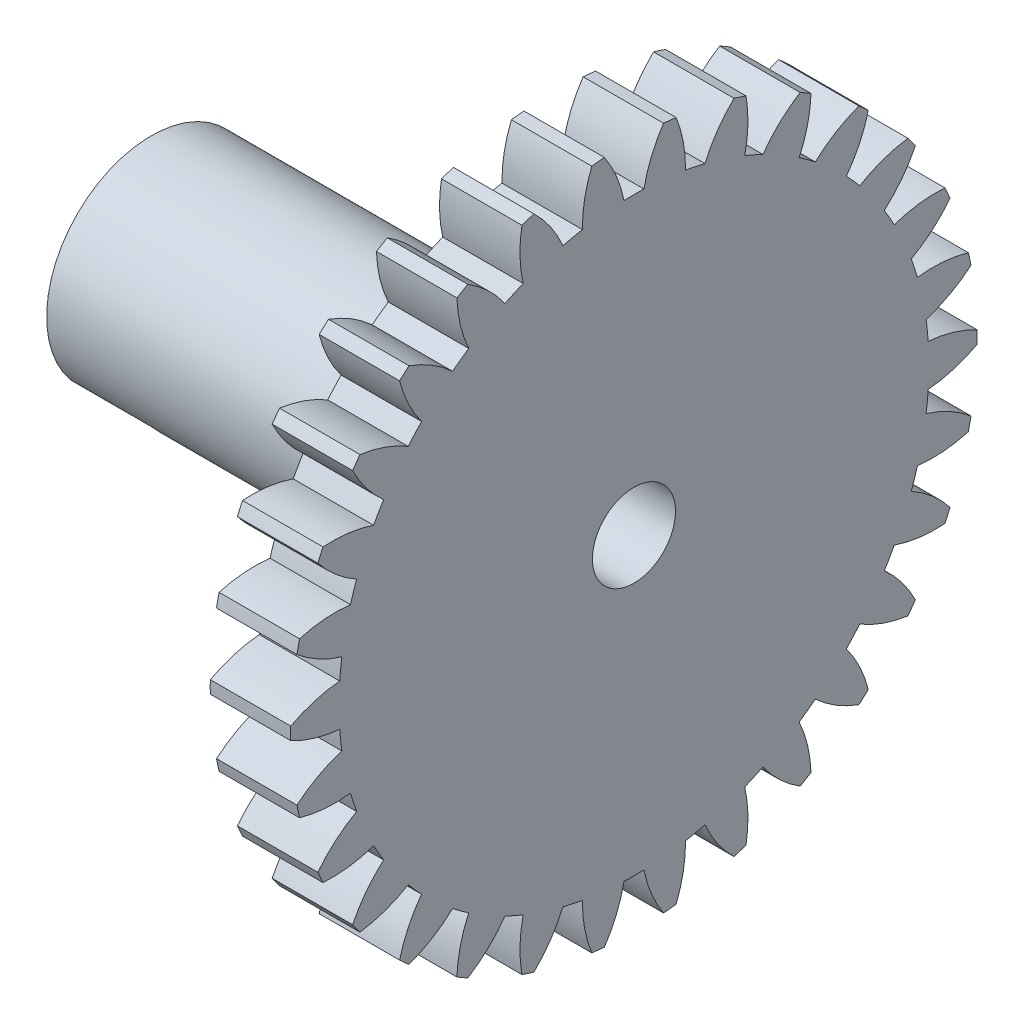
from build123d import *

# Parameters (mm, degrees)
BASPROSKE_W         = 5.5
BASPROSKE_H         = 12.8
TOOTHCUT_DEPTH      = 19.919038031
TEETHCUTS_COUNT     = 30
HUBNEAONESKE_R      = 1.9
HUBNEARONE_DEPTH    = 5.5000508
BORSKE_R            = 0.4
BORE_DEPTH          = 11.0000508
SKETCH1_R           = 3.9
BOSS_EXTRUDE1_DEPTH = 15
SKETCH2_R           = 1.55
CUT_EXTRUDE1_DEPTH  = 28
CUT_EXTRUDE2_DEPTH  = 3
CUT_EXTRUDE3_DEPTH  = 2.5


with BuildPart() as part:
    # BasProSke → Base-Revolve (revolve)
    with BuildSketch(Plane(origin=(0, 0, 0), x_dir=(1, 0, 0), z_dir=(0, 1, 0)), mode=Mode.PRIVATE) as base_revolve_sk:
        with Locations((2.75, 6.4)):
            Rectangle(BASPROSKE_W, BASPROSKE_H)
    revolve(base_revolve_sk.sketch.rotate(Axis((-10, 0, 0), (1, 0, 0)), 180), axis=Axis((-10, 0, 0), (1, 0, 0)))

    # TooCutSke → ToothCut (cut, through all)
    with BuildSketch(Plane(origin=(0, 0, 0), x_dir=(0, 0, -1), z_dir=(1, 0, 0))):
        with BuildLine():
            ThreePointArc((0.37243947, 10.992692566), (0, 10.999), (-0.37243947, 10.992692566))
            ThreePointArc((-0.37243947, 10.992692566), (-0.655704499, 11.922595954), (-1.120515575, 12.776358245))
            ThreePointArc((-1.120515575, 12.776358245), (0, 12.8254), (1.120515575, 12.776358245))
            ThreePointArc((1.120515575, 12.776358245), (0.655704499, 11.922595954), (0.37243947, 10.992692566))
        make_face()
    toothcut = extrude(amount=TOOTHCUT_DEPTH, mode=Mode.SUBTRACT)

    # TeethCuts: ToothCut ×30 about axis
    teethcuts_axis = Axis((0, 0, 0), (1, 0, 0))
    for i in range(1, TEETHCUTS_COUNT):
        add(toothcut.rotate(teethcuts_axis, i * 360 / TEETHCUTS_COUNT), mode=Mode.SUBTRACT)

    # HubNeaOneSke → HubNearOne (add)
    with BuildSketch(Plane.ZY):
        with Locations(Location((0, 0, 0), (0, 0, 180))):
            Circle(HUBNEAONESKE_R)
    extrude(amount=HUBNEARONE_DEPTH)

    # BorSke → Bore (cut, symmetric)
    with BuildSketch(Plane(origin=(0, 0, 0), x_dir=(0, 0, -1), z_dir=(1, 0, 0))):
        with Locations(Location((0, 0, 0), (0, 0, 180))):
            Circle(BORSKE_R)
    extrude(amount=BORE_DEPTH, both=True, mode=Mode.SUBTRACT)

    # Sketch1 → Boss-Extrude1 (add)
    with BuildSketch(Plane.ZY):
        with Locations(Location((0, 0, 0), (0, 0, 180))):
            Circle(SKETCH1_R)
    extrude(amount=BOSS_EXTRUDE1_DEPTH)

    # Sketch2 → Cut-Extrude1 (cut)
    with BuildSketch(Plane.ZY.offset(15)):
        Circle(SKETCH2_R)
    extrude(amount=-CUT_EXTRUDE1_DEPTH, mode=Mode.SUBTRACT)

    # Sketch3 → Cut-Extrude2 (cut)
    with BuildSketch(Plane.ZY.offset(15)):
        with BuildLine():
            Line((-3, -2.491987159), (3, -2.491987159))
            ThreePointArc((3, -2.491987159), (0, -3.9), (-3, -2.491987159))
        make_face()
    extrude(amount=-CUT_EXTRUDE2_DEPTH, mode=Mode.SUBTRACT)

    # Sketch4 → Cut-Extrude3 (cut)
    with BuildSketch(Plane(origin=(5.5, 0, 0), x_dir=(0, 0, -1), z_dir=(1, 0, 0))):
        with BuildLine():
            ThreePointArc((-12.797844972, -0.234870354), (-11.911881767, -0.598311695), (-10.971403971, -0.778650053))
            ThreePointArc((-10.971403971, -0.778650053), (-10.938746327, -1.149708567), (-10.89354292, -1.519448469))
            ThreePointArc((-10.89354292, -1.519448469), (-11.775974567, -1.89138233), (-12.567013646, -2.431083714))
            ThreePointArc((-12.567013646, -2.431083714), (-12.520289289, -2.661269642), (-12.469349061, -2.89055946))
            ThreePointArc((-12.469349061, -2.89055946), (-11.527182574, -3.061856628), (-10.569762022, -3.042717832))
            ThreePointArc((-10.569762022, -3.042717832), (-10.460670623, -3.398877921), (-10.339581771, -3.751139802))
            ThreePointArc((-10.339581771, -3.751139802), (-11.125400771, -4.298413871), (-11.786943521, -4.990787758))
            ThreePointArc((-11.786943521, -4.990787758), (-11.693381858, -5.206229031), (-11.595882762, -5.419917247))
            ThreePointArc((-11.595882762, -5.419917247), (-10.63869019, -5.391583734), (-9.706170753, -5.17380424))
            ThreePointArc((-9.706170753, -5.17380424), (-9.525413416, -5.4995), (-9.333731283, -5.818888325))
            ThreePointArc((-9.333731283, -5.818888325), (-9.988593575, -6.517584101), (-10.491727404, -7.332370428))
            ThreePointArc((-10.491727404, -7.332370428), (-10.355417528, -7.523651229), (-10.215620743, -7.712398643))
            ThreePointArc((-10.215620743, -7.712398643), (-9.285235994, -7.485672759), (-8.418373247, -7.078770577))
            ThreePointArc((-8.418373247, -7.078770577), (-8.173849935, -7.359767539), (-7.91995195, -7.632323507))
            ThreePointArc((-7.91995195, -7.632323507), (-8.41523691, -8.45190463), (-8.737972454, -9.353493326))
            ThreePointArc((-8.737972454, -9.353493326), (-8.564871761, -9.512253766), (-8.388887078, -9.66781121))
            ThreePointArc((-8.388887078, -9.66781121), (-7.52597243, -9.252601964), (-6.762652434, -8.674360672))
            ThreePointArc((-6.762652434, -8.674360672), (-6.46504999, -8.898377921), (-6.160032712, -9.112189527))
            ThreePointArc((-6.160032712, -9.112189527), (-6.474094011, -10.01683637), (-6.602326179, -10.965823682))
            ThreePointArc((-6.602326179, -10.965823682), (-6.4, -11.085125168), (-6.195518793, -11.200694036))
            ThreePointArc((-6.195518793, -11.200694036), (-5.437787756, -10.615148065), (-4.811371258, -9.890839581))
            ThreePointArc((-4.811371258, -9.890839581), (-4.473696337, -10.048086489), (-4.130890486, -10.19380914))
            ThreePointArc((-4.130890486, -10.19380914), (-4.250002137, -11.143984294), (-4.178126568, -12.098894924))
            ThreePointArc((-4.178126568, -12.098894924), (-3.955417528, -12.173523409), (-3.731376607, -12.244052786))
            ThreePointArc((-3.731376607, -12.244052786), (-3.111945665, -11.513761258), (-2.649810072, -10.675041339))
            ThreePointArc((-2.649810072, -10.675041339), (-2.286820687, -10.75864546), (-1.921208524, -10.829910379))
            ThreePointArc((-1.921208524, -10.829910379), (-1.840164777, -11.78408663), (-1.571322777, -12.703186401))
            ThreePointArc((-1.571322777, -12.703186401), (-1.33796433, -12.729880261), (-1.104155359, -12.752287675))
            ThreePointArc((-1.104155359, -12.752287675), (-0.650096615, -11.909167834), (-0.37243947, -10.992692566))
            ThreePointArc((-0.37243947, -10.992692566), (0, -10.999), (0.37243947, -10.992692566))
            ThreePointArc((0.37243947, -10.992692566), (0.650096615, -11.909167834), (1.104155359, -12.752287675))
            ThreePointArc((1.104155359, -12.752287675), (1.33796433, -12.729880261), (1.571322777, -12.703186401))
            ThreePointArc((1.571322777, -12.703186401), (1.840164777, -11.78408663), (1.921208524, -10.829910379))
            ThreePointArc((1.921208524, -10.829910379), (2.286820687, -10.75864546), (2.649810072, -10.675041339))
            ThreePointArc((2.649810072, -10.675041339), (3.111945665, -11.513761258), (3.731376607, -12.244052786))
            ThreePointArc((3.731376607, -12.244052786), (3.955417528, -12.173523409), (4.178126568, -12.098894924))
            ThreePointArc((4.178126568, -12.098894924), (4.250002137, -11.143984294), (4.130890486, -10.19380914))
            ThreePointArc((4.130890486, -10.19380914), (4.473696337, -10.048086489), (4.811371258, -9.890839581))
            ThreePointArc((4.811371258, -9.890839581), (5.437787756, -10.615148065), (6.195518793, -11.200694036))
            ThreePointArc((6.195518793, -11.200694036), (6.4, -11.085125168), (6.602326179, -10.965823682))
            ThreePointArc((6.602326179, -10.965823682), (6.474094011, -10.01683637), (6.160032712, -9.112189527))
            ThreePointArc((6.160032712, -9.112189527), (6.46504999, -8.898377921), (6.762652434, -8.674360672))
            ThreePointArc((6.762652434, -8.674360672), (7.52597243, -9.252601964), (8.388887078, -9.66781121))
            ThreePointArc((8.388887078, -9.66781121), (8.564871761, -9.512253766), (8.737972454, -9.353493326))
            ThreePointArc((8.737972454, -9.353493326), (8.41523691, -8.45190463), (7.91995195, -7.632323507))
            ThreePointArc((7.91995195, -7.632323507), (8.173849935, -7.359767539), (8.418373247, -7.078770577))
            ThreePointArc((8.418373247, -7.078770577), (9.285235994, -7.485672759), (10.215620743, -7.712398643))
            ThreePointArc((10.215620743, -7.712398643), (10.355417528, -7.523651229), (10.491727404, -7.332370428))
            ThreePointArc((10.491727404, -7.332370428), (9.988593575, -6.517584101), (9.333731283, -5.818888325))
            ThreePointArc((9.333731283, -5.818888325), (9.525413416, -5.4995), (9.706170753, -5.17380424))
            ThreePointArc((9.706170753, -5.17380424), (10.63869019, -5.391583734), (11.595882762, -5.419917247))
            ThreePointArc((11.595882762, -5.419917247), (11.693381858, -5.206229031), (11.786943521, -4.990787758))
            ThreePointArc((11.786943521, -4.990787758), (11.125400771, -4.298413871), (10.339581771, -3.751139802))
            ThreePointArc((10.339581771, -3.751139802), (10.460670623, -3.398877921), (10.569762022, -3.042717832))
            ThreePointArc((10.569762022, -3.042717832), (11.527182574, -3.061856628), (12.469349061, -2.89055946))
            ThreePointArc((12.469349061, -2.89055946), (12.520289289, -2.661269642), (12.567013646, -2.431083714))
            ThreePointArc((12.567013646, -2.431083714), (11.775974567, -1.89138233), (10.89354292, -1.519448469))
            ThreePointArc((10.89354292, -1.519448469), (10.938746327, -1.149708567), (10.971403971, -0.778650053))
            ThreePointArc((10.971403971, -0.778650053), (11.911881767, -0.598311695), (12.797844972, -0.234870354))
            ThreePointArc((12.797844972, -0.234870354), (12.8, 0), (12.797844972, 0.234870354))
            ThreePointArc((12.797844972, 0.234870354), (11.911881767, 0.598311695), (10.971403971, 0.778650053))
            ThreePointArc((10.971403971, 0.778650053), (10.938746327, 1.149708567), (10.89354292, 1.519448469))
            ThreePointArc((10.89354292, 1.519448469), (11.775974567, 1.89138233), (12.567013646, 2.431083714))
            ThreePointArc((12.567013646, 2.431083714), (12.520289289, 2.661269642), (12.469349061, 2.89055946))
            ThreePointArc((12.469349061, 2.89055946), (11.527182574, 3.061856628), (10.569762022, 3.042717832))
            ThreePointArc((10.569762022, 3.042717832), (10.460670623, 3.398877921), (10.339581771, 3.751139802))
            ThreePointArc((10.339581771, 3.751139802), (11.125400771, 4.298413871), (11.786943521, 4.990787758))
            ThreePointArc((11.786943521, 4.990787758), (11.693381858, 5.206229031), (11.595882762, 5.419917247))
            ThreePointArc((11.595882762, 5.419917247), (10.63869019, 5.391583734), (9.706170753, 5.17380424))
            ThreePointArc((9.706170753, 5.17380424), (9.525413416, 5.4995), (9.333731283, 5.818888325))
            ThreePointArc((9.333731283, 5.818888325), (9.988593575, 6.517584101), (10.491727404, 7.332370428))
            ThreePointArc((10.491727404, 7.332370428), (10.355417528, 7.523651229), (10.215620743, 7.712398643))
            ThreePointArc((10.215620743, 7.712398643), (9.285235994, 7.485672759), (8.418373247, 7.078770577))
            ThreePointArc((8.418373247, 7.078770577), (8.173849935, 7.359767539), (7.91995195, 7.632323507))
            ThreePointArc((7.91995195, 7.632323507), (8.41523691, 8.45190463), (8.737972454, 9.353493326))
            ThreePointArc((8.737972454, 9.353493326), (8.564871761, 9.512253766), (8.388887078, 9.66781121))
            ThreePointArc((8.388887078, 9.66781121), (7.52597243, 9.252601964), (6.762652434, 8.674360672))
            ThreePointArc((6.762652434, 8.674360672), (6.46504999, 8.898377921), (6.160032712, 9.112189527))
            ThreePointArc((6.160032712, 9.112189527), (6.474094011, 10.01683637), (6.602326179, 10.965823682))
            ThreePointArc((6.602326179, 10.965823682), (6.4, 11.085125168), (6.195518793, 11.200694036))
            ThreePointArc((6.195518793, 11.200694036), (5.437787756, 10.615148065), (4.811371258, 9.890839581))
            ThreePointArc((4.811371258, 9.890839581), (4.473696337, 10.048086489), (4.130890486, 10.19380914))
            ThreePointArc((4.130890486, 10.19380914), (4.250002137, 11.143984294), (4.178126568, 12.098894924))
            ThreePointArc((4.178126568, 12.098894924), (3.955417528, 12.173523409), (3.731376607, 12.244052786))
            ThreePointArc((3.731376607, 12.244052786), (3.111945665, 11.513761258), (2.649810072, 10.675041339))
            ThreePointArc((2.649810072, 10.675041339), (2.286820687, 10.75864546), (1.921208524, 10.829910379))
            ThreePointArc((1.921208524, 10.829910379), (1.840164777, 11.78408663), (1.571322777, 12.703186401))
            ThreePointArc((1.571322777, 12.703186401), (1.33796433, 12.729880261), (1.104155359, 12.752287675))
            ThreePointArc((1.104155359, 12.752287675), (0.650096615, 11.909167834), (0.37243947, 10.992692566))
            ThreePointArc((0.37243947, 10.992692566), (0, 10.999), (-0.37243947, 10.992692566))
            ThreePointArc((-0.37243947, 10.992692566), (-0.650096615, 11.909167834), (-1.104155359, 12.752287675))
            ThreePointArc((-1.104155359, 12.752287675), (-1.33796433, 12.729880261), (-1.571322777, 12.703186401))
            ThreePointArc((-1.571322777, 12.703186401), (-1.840164777, 11.78408663), (-1.921208524, 10.829910379))
            ThreePointArc((-1.921208524, 10.829910379), (-2.286820687, 10.75864546), (-2.649810072, 10.675041339))
            ThreePointArc((-2.649810072, 10.675041339), (-3.111945665, 11.513761258), (-3.731376607, 12.244052786))
            ThreePointArc((-3.731376607, 12.244052786), (-3.955417528, 12.173523409), (-4.178126568, 12.098894924))
            ThreePointArc((-4.178126568, 12.098894924), (-4.250002137, 11.143984294), (-4.130890486, 10.19380914))
            ThreePointArc((-4.130890486, 10.19380914), (-4.473696337, 10.048086489), (-4.811371258, 9.890839581))
            ThreePointArc((-4.811371258, 9.890839581), (-5.437787756, 10.615148065), (-6.195518793, 11.200694036))
            ThreePointArc((-6.195518793, 11.200694036), (-6.4, 11.085125168), (-6.602326179, 10.965823682))
            ThreePointArc((-6.602326179, 10.965823682), (-6.474094011, 10.01683637), (-6.160032712, 9.112189527))
            ThreePointArc((-6.160032712, 9.112189527), (-6.46504999, 8.898377921), (-6.762652434, 8.674360672))
            ThreePointArc((-6.762652434, 8.674360672), (-7.52597243, 9.252601964), (-8.388887078, 9.66781121))
            ThreePointArc((-8.388887078, 9.66781121), (-8.564871761, 9.512253766), (-8.737972454, 9.353493326))
            ThreePointArc((-8.737972454, 9.353493326), (-8.41523691, 8.45190463), (-7.91995195, 7.632323507))
            ThreePointArc((-7.91995195, 7.632323507), (-8.173849935, 7.359767539), (-8.418373247, 7.078770577))
            ThreePointArc((-8.418373247, 7.078770577), (-9.285235994, 7.485672759), (-10.215620743, 7.712398643))
            ThreePointArc((-10.215620743, 7.712398643), (-10.355417528, 7.523651229), (-10.491727404, 7.332370428))
            ThreePointArc((-10.491727404, 7.332370428), (-9.988593575, 6.517584101), (-9.333731283, 5.818888325))
            ThreePointArc((-9.333731283, 5.818888325), (-9.525413416, 5.4995), (-9.706170753, 5.17380424))
            ThreePointArc((-9.706170753, 5.17380424), (-10.63869019, 5.391583734), (-11.595882762, 5.419917247))
            ThreePointArc((-11.595882762, 5.419917247), (-11.693381858, 5.206229031), (-11.786943521, 4.990787758))
            ThreePointArc((-11.786943521, 4.990787758), (-11.125400771, 4.298413871), (-10.339581771, 3.751139802))
            ThreePointArc((-10.339581771, 3.751139802), (-10.460670623, 3.398877921), (-10.569762022, 3.042717832))
            ThreePointArc((-10.569762022, 3.042717832), (-11.527182574, 3.061856628), (-12.469349061, 2.89055946))
            ThreePointArc((-12.469349061, 2.89055946), (-12.520289289, 2.661269642), (-12.567013646, 2.431083714))
            ThreePointArc((-12.567013646, 2.431083714), (-11.775974567, 1.89138233), (-10.89354292, 1.519448469))
            ThreePointArc((-10.89354292, 1.519448469), (-10.938746327, 1.149708567), (-10.971403971, 0.778650053))
            ThreePointArc((-10.971403971, 0.778650053), (-11.911881767, 0.598311695), (-12.797844972, 0.234870354))
            ThreePointArc((-12.797844972, 0.234870354), (-12.8, 0), (-12.797844972, -0.234870354))
        make_face()
    extrude(amount=-CUT_EXTRUDE3_DEPTH, mode=Mode.SUBTRACT)


solid = part.part
